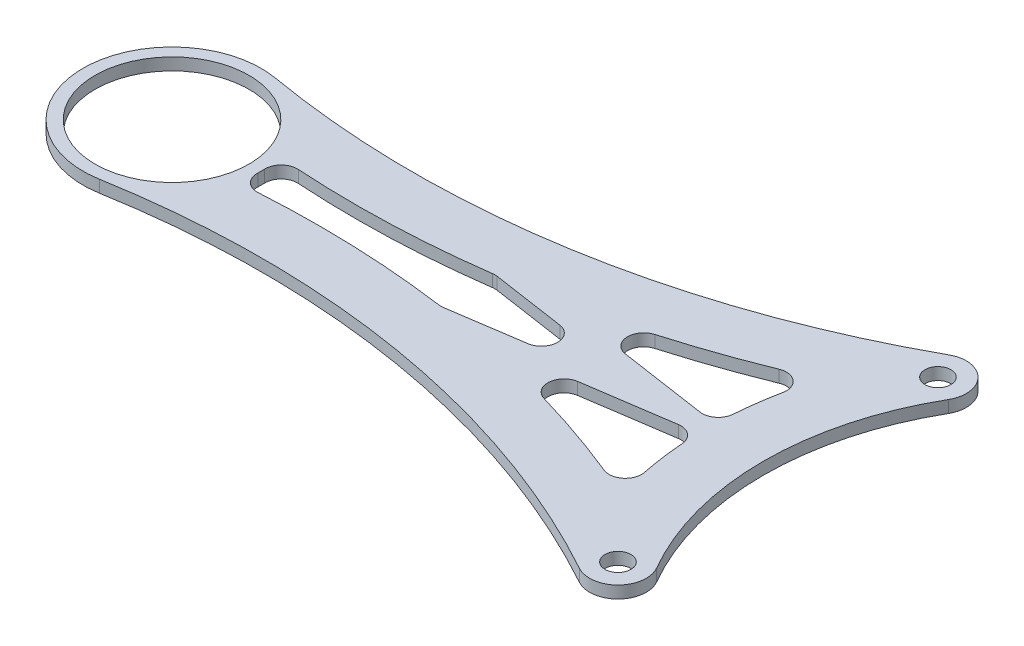
from build123d import *

# Parameters (mm, degrees)
SKETCH1_R                      = 3.5
BOSS_EXTRUDE1_DEPTH            = 0.75
F_3_2_3_2_DIAMETER_HOLE1_D     = 3.2
F_3_2_3_2_DIAMETER_HOLE1_DEPTH = 10
F_3_2_3_2_DIAMETER_HOLE1_TIP   = 0.96137699
CUT_EXTRUDE1_DEPTH             = 2.5
FILLET1_R                      = 2
SKETCH7_R                      = 9.5
CUT_EXTRUDE2_DEPTH             = 2.5000001


with BuildPart() as part:
    # Sketch1 → Boss-Extrude1 (new body, symmetric)
    with BuildSketch(Plane(origin=(0, 0, 0), x_dir=(1, 0, 0), z_dir=(0, 1, 0))):
        with BuildLine():
            ThreePointArc((-37.239092363, -21.5), (-43, 0), (-37.239092363, 21.5))
            ThreePointArc((-37.239092363, 21.5), (-36.658838331, 22.248681329), (-35.899079455, 22.81435343))
            ThreePointArc((-35.899079455, 22.81435343), (-70.492179883, 10.7556392), (-107.126701642, 10.839315166))
            ThreePointArc((-107.126701642, 10.839315166), (-120, 0), (-107.126701642, -10.839315166))
            ThreePointArc((-107.126701642, -10.839315166), (-70.492179883, -10.7556392), (-35.899079455, -22.81435343))
            ThreePointArc((-35.899079455, -22.81435343), (-36.658838331, -22.248681329), (-37.239092363, -21.5))
        make_face()
        with BuildLine():
            ThreePointArc((-31.176914536, 18), (-35.958003449, 16.718911087), (-37.239092363, 21.5))
            ThreePointArc((-37.239092363, 21.5), (-43, 0), (-37.239092363, -21.5))
            ThreePointArc((-37.239092363, -21.5), (-35.958003449, -16.718911087), (-31.176914536, -18))
            ThreePointArc((-31.176914536, -18), (-36, 0), (-31.176914536, 18))
        make_face()
        with Locations((-34.208003449, -19.75)):
            Circle(SKETCH1_R)
        with Locations((-34.208003449, 19.75)):
            Circle(SKETCH1_R)
    extrude(amount=BOSS_EXTRUDE1_DEPTH, both=True)

    # Ø3.2 (3.2) Diameter Hole1
    with Locations(Plane(origin=(0, 0.75, 0), x_dir=(1, 0, 0), z_dir=(0, 1, 0))):
        with Locations((-34.208003449, 19.75), (-34.208003449, -19.75), (-106.530652164, 14.288188173), (-106.530652164, -14.288188173)):
            Hole(F_3_2_3_2_DIAMETER_HOLE1_D / 2, depth=F_3_2_3_2_DIAMETER_HOLE1_DEPTH)
            with Locations((0, 0, -(F_3_2_3_2_DIAMETER_HOLE1_DEPTH + F_3_2_3_2_DIAMETER_HOLE1_TIP / 2))):  # 118° drill point
                Cone(0, F_3_2_3_2_DIAMETER_HOLE1_D / 2, F_3_2_3_2_DIAMETER_HOLE1_TIP, mode=Mode.SUBTRACT)

    # Sketch6 → Cut-Extrude1 (cut, through all)
    with BuildSketch(Plane(origin=(0, 0.75, 0), x_dir=(1, 0, 0), z_dir=(0, 1, 0))):
        with BuildLine():
            Line((-72.469338063, -3.369046694), (-49.802019621, 0))
            Line((-49.802019621, 0), (-72.469338063, 3.369046694))
            ThreePointArc((-72.469338063, 3.369046694), (-85.377857375, 2.290839769), (-98.326107181, 2.65857332))
            ThreePointArc((-98.326107181, 2.65857332), (-98, 0), (-98.326107181, -2.65857332))
            ThreePointArc((-98.326107181, -2.65857332), (-85.377857375, -2.290839769), (-72.469338063, -3.369046694))
        make_face()
        with BuildLine():
            Line((-66.096117167, 4.443764231), (-42.988154947, 1.009224591))
            ThreePointArc((-42.988154947, 1.009224591), (-42.467311238, 6.747405149), (-41.183985346, 12.36443897))
            ThreePointArc((-41.183985346, 12.36443897), (-53.416219701, 7.70010587), (-66.096117167, 4.443764231))
        make_face()
        with BuildLine():
            ThreePointArc((-41.183985346, -12.36443897), (-42.467311238, -6.747405149), (-42.988154947, -1.009224591))
            Line((-42.988154947, -1.009224591), (-66.096117167, -4.443764231))
            ThreePointArc((-66.096117167, -4.443764231), (-53.416219701, -7.70010587), (-41.183985346, -12.36443897))
        make_face()
    extrude(amount=-CUT_EXTRUDE1_DEPTH, mode=Mode.SUBTRACT)

    # Fillet1
    fillet1_edges = [part.edges().sort_by_distance(p)[0] for p in [
        (-98.326107181, 0, 2.65857332),
        (-98.326107181, 0, -2.65857332),
        (-72.469338063, 0, -3.369046694),
        (-49.802019621, 0, 0),
        (-72.469338063, 0, 3.369046694),
        (-41.183985346, 0, -12.36443897),
        (-42.988154947, 0, -1.009224591),
        (-66.096117167, 0, -4.443764231),
        (-42.988154947, 0, 1.009224591),
        (-41.183985346, 0, 12.36443897),
        (-66.096117167, 0, 4.443764231),
    ]]
    fillet(fillet1_edges, radius=FILLET1_R)

    # Sketch7 → Cut-Extrude2 (cut, through all)
    with BuildSketch(Plane(origin=(0, 0.75, 0), x_dir=(1, 0, 0), z_dir=(0, 1, 0))):
        with Locations((-109, 0)):
            Circle(SKETCH7_R)
    extrude(amount=-CUT_EXTRUDE2_DEPTH, mode=Mode.SUBTRACT)


solid = part.part
